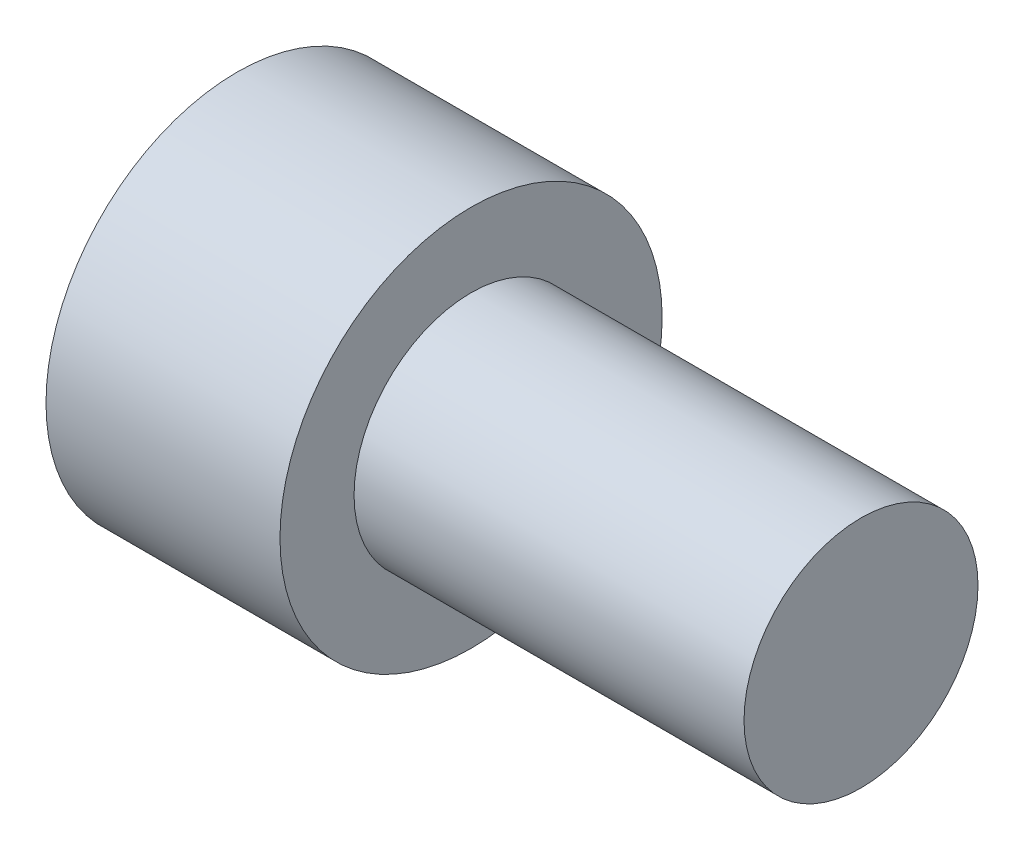
from build123d import *

# Parameters (mm, degrees)
SKETCH4_R           = 9.525
BOSS_EXTRUDE1_DEPTH = 31.75


with BuildPart() as part:
    # Sketch1 → Revolve1 (revolve)
    with BuildSketch(Plane(origin=(0, 0, 0), x_dir=(1, 0, 0), z_dir=(0, 1, 0))):
        Polygon((19.05, 15.5575), (19.05, 0), (0, 0), (0, 15.5575), (0.79, 15.5575), (8.73, 15.5575), align=None)
    revolve(axis=Axis((0, 0, 0), (1, 0, 0)))

    # Sketch4 → Boss-Extrude1 (add)
    with BuildSketch(Plane(origin=(19.05, 0, 0), x_dir=(0, 0, -1), z_dir=(1, 0, 0))):
        Circle(SKETCH4_R)
    extrude(amount=BOSS_EXTRUDE1_DEPTH)


solid = part.part
